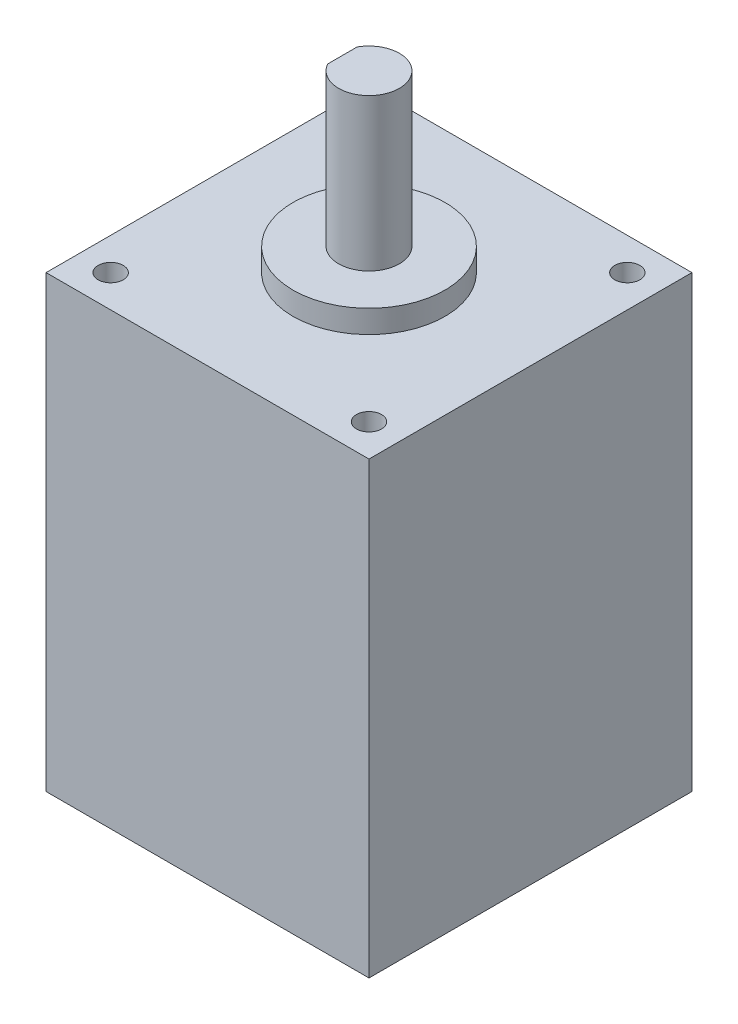
from build123d import *

# Parameters (mm, degrees)
SKETCH_1_W          = 42.5
SKETCH_1_H          = 42.5
EXTRUDE_1_DEPTH     = 59.15
SKETCH_2_R          = 10
EXTRUDE_2_DEPTH     = 3
SKETCH_3_R          = 4
EXTRUDE_3_DEPTH     = 20
HOLE_WIZARD_3_D     = 3.3
HOLE_WIZARD_3_DEPTH = 11.5
HOLE_WIZARD_3_TIP   = 0.991420021
EXTRUDE_4_DEPTH     = 12


with BuildPart() as part:
    # 스케치1 → 돌출1 (new body)
    with BuildSketch(Plane(origin=(0, 0, 0), x_dir=(-1, 0, 0), z_dir=(0, 1, 0))):
        with Locations((21.25, -21.25)):
            Rectangle(SKETCH_1_W, SKETCH_1_H)
    extrude(amount=EXTRUDE_1_DEPTH)

    # 스케치2 → 돌출2 (add)
    with BuildSketch(Plane(origin=(0, 59.15, 0), x_dir=(-1, 0, 0), z_dir=(0, 1, 0))):
        with Locations((21.25, -21.25)):
            Circle(SKETCH_2_R)
    extrude(amount=EXTRUDE_2_DEPTH)

    # 스케치3 → 돌출3 (add)
    with BuildSketch(Plane(origin=(0, 62.15, 0), x_dir=(-1, 0, 0), z_dir=(0, 1, 0))):
        with Locations((21.25, -21.25)):
            Circle(SKETCH_3_R)
    extrude(amount=EXTRUDE_3_DEPTH)

    # 구멍3
    with Locations(Plane(origin=(0, 59.15, 0), x_dir=(1, 0, 0), z_dir=(0, 1, 0))):
        with Locations((-4.25, 38.25), (-4.25, 4.25), (-38.25, 4.25), (-38.25, 38.25)):
            Hole(HOLE_WIZARD_3_D / 2, depth=HOLE_WIZARD_3_DEPTH)
            with Locations((0, 0, -(HOLE_WIZARD_3_DEPTH + HOLE_WIZARD_3_TIP / 2))):  # 118° drill point
                Cone(0, HOLE_WIZARD_3_D / 2, HOLE_WIZARD_3_TIP, mode=Mode.SUBTRACT)

    # 스케치6 → 돌출4 (cut)
    with BuildSketch(Plane(origin=(0, 82.15, 0), x_dir=(-1, 0, 0), z_dir=(0, 1, 0))):
        with BuildLine():
            Line((24.75, -19.313508327), (24.75, -23.186491673))
            ThreePointArc((24.75, -23.186491673), (25.25, -21.25), (24.75, -19.313508327))
        make_face()
    extrude(amount=-EXTRUDE_4_DEPTH, mode=Mode.SUBTRACT)


solid = part.part
